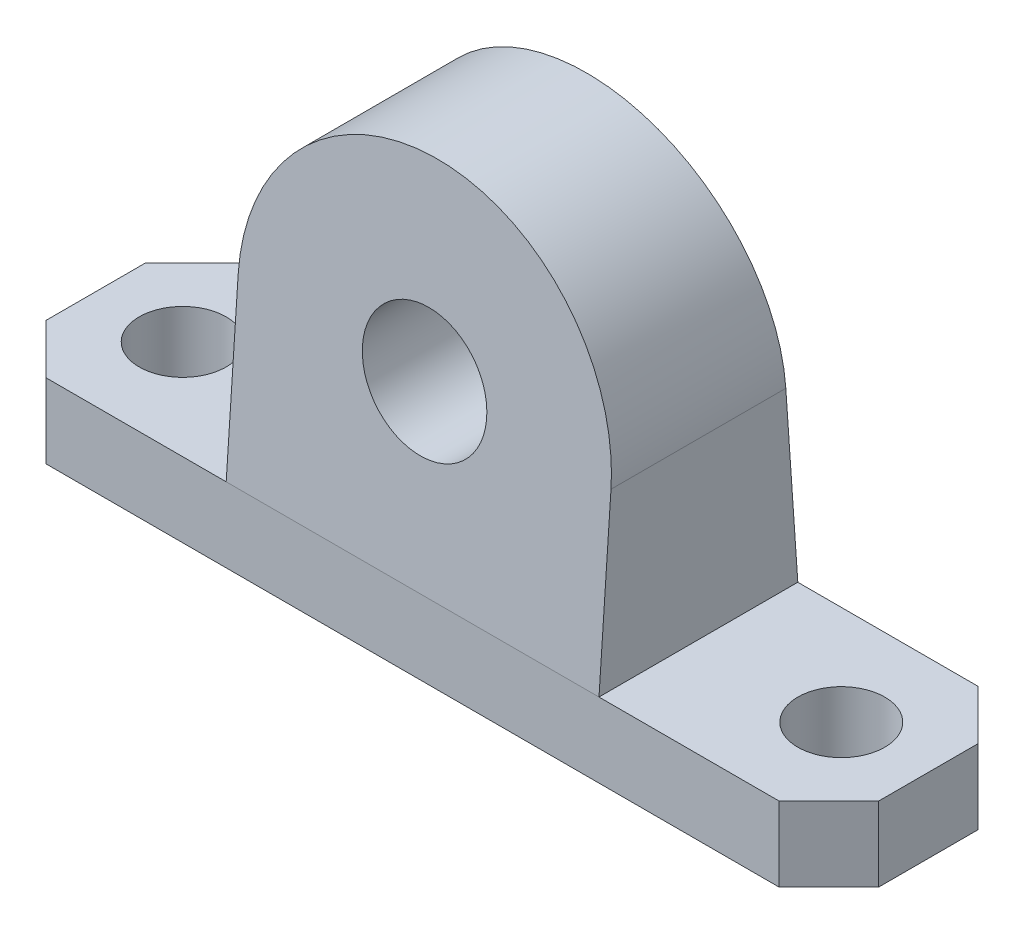
from build123d import *

# Parameters (mm, degrees)
BOSS_EXTRUDE2_DEPTH             = 6
SKETCH3_W                       = 30
SKETCH3_H                       = 16
BOSS_EXTRUDE3_DEPTH             = 29
CUT_EXTRUDE1_DEPTH              = 16
CUT_EXTRUDE2_DEPTH              = 30
SKETCH6_R                       = 3.5
CUT_EXTRUDE3_DEPTH              = 6
CUT_EXTRUDE4_REACH              = 18
SKETCH7_R                       = 5
BOSS_EXTRUDE4_REACH             = 18
SKETCH8_R                       = 7
SKETCH8_R_2                     = 5
BOSS_EXTRUDE4_DIRECTION_2_DEPTH = 1


with BuildPart() as part:
    # Sketch2 → Boss-Extrude2 (new body)
    with BuildSketch(Plane(origin=(0, 0, 0), x_dir=(1, 0, 0), z_dir=(0, 1, 0))):
        Polygon((-29.5, 8), (-33.5, 4), (-33.5, -4), (-29.5, -8), (29.5, -8), (33.5, -4), (33.5, 4), (29.5, 8), align=None)
    extrude(amount=BOSS_EXTRUDE2_DEPTH)

    # Sketch3 → Boss-Extrude3 (add)
    with BuildSketch(Plane(origin=(0, 6, 0), x_dir=(1, 0, 0), z_dir=(0, 1, 0))):
        Rectangle(SKETCH3_W, SKETCH3_H)
    extrude(amount=BOSS_EXTRUDE3_DEPTH)

    # Sketch4 → Cut-Extrude1 (cut)
    with BuildSketch(Plane.XY.offset(8)):
        with BuildLine():
            ThreePointArc((-15, 20), (-10.606601718, 30.606601718), (0, 35))
            Line((0, 35), (-15, 35))
            Line((-15, 35), (-15, 20))
        make_face()
        with BuildLine():
            Line((15, 20), (15, 35))
            Line((15, 35), (0, 35))
            ThreePointArc((0, 35), (10.606601718, 30.606601718), (15, 20))
        make_face()
    extrude(amount=-CUT_EXTRUDE1_DEPTH, mode=Mode.SUBTRACT)

    # Sketch5 → Cut-Extrude2 (cut)
    with BuildSketch(Plane.ZY.offset(15)):
        Polygon((-6, 35), (-8, 6), (-8, 35), align=None)
        Polygon((8, 6), (6, 35), (8, 35), align=None)
    extrude(amount=-CUT_EXTRUDE2_DEPTH, mode=Mode.SUBTRACT)

    # Sketch6 → Cut-Extrude3 (cut)
    with BuildSketch(Plane.XZ):
        with Locations((-26.5, 0)):
            Circle(SKETCH6_R)
        with Locations((26.5, 0)):
            Circle(SKETCH6_R)
    extrude(amount=-CUT_EXTRUDE3_DEPTH, mode=Mode.SUBTRACT)

    # Cut-Extrude4: up to this face of the body (flat: up to its plane)
    cut_extrude4_end = Plane(part.part.faces().sort_by_distance((0, 19.107869184, 7.096009022))[0])
    # Sketch7 → Cut-Extrude4 (cut, up to the picked face)
    with BuildSketch(Plane(origin=(0, 0, -8), x_dir=(-1, 0, 0), z_dir=(0, 0, -1)), mode=Mode.PRIVATE) as cut_extrude4_sk1:
        with Locations((0, 20)):
            Circle(SKETCH7_R)
    cut_extrude4_tool1 = split(extrude(cut_extrude4_sk1.sketch, amount=-CUT_EXTRUDE4_REACH, mode=Mode.PRIVATE), bisect_by=cut_extrude4_end, keep=Keep.BOTH, mode=Mode.PRIVATE)
    add(cut_extrude4_tool1.solids().sort_by_distance((0, 20, -8))[0], mode=Mode.SUBTRACT)

    # Sketch8 → Boss-Extrude4 (add, up to next)
    with BuildSketch(Plane(origin=(0, 0, -8), x_dir=(-1, 0, 0), z_dir=(0, 0, -1)), mode=Mode.PRIVATE) as boss_extrude4_sk1:
        with Locations((0, 20)):
            Circle(SKETCH8_R)
        with Locations((0, 20)):
            Circle(SKETCH8_R_2, mode=Mode.SUBTRACT)
    boss_extrude4_tool1 = extrude(boss_extrude4_sk1.sketch, amount=-BOSS_EXTRUDE4_REACH, mode=Mode.PRIVATE) - part.part
    add(boss_extrude4_tool1.solids().sort_by_distance((6.80201, 20, -8))[0])

    # Sketch8 → Boss-Extrude4 direction 2 (add)
    with BuildSketch(Plane(origin=(0, 0, -8), x_dir=(-1, 0, 0), z_dir=(0, 0, -1))):
        with Locations((0, 20)):
            Circle(SKETCH8_R)
        with Locations((0, 20)):
            Circle(SKETCH8_R_2, mode=Mode.SUBTRACT)
    extrude(amount=BOSS_EXTRUDE4_DIRECTION_2_DEPTH)


solid = part.part
